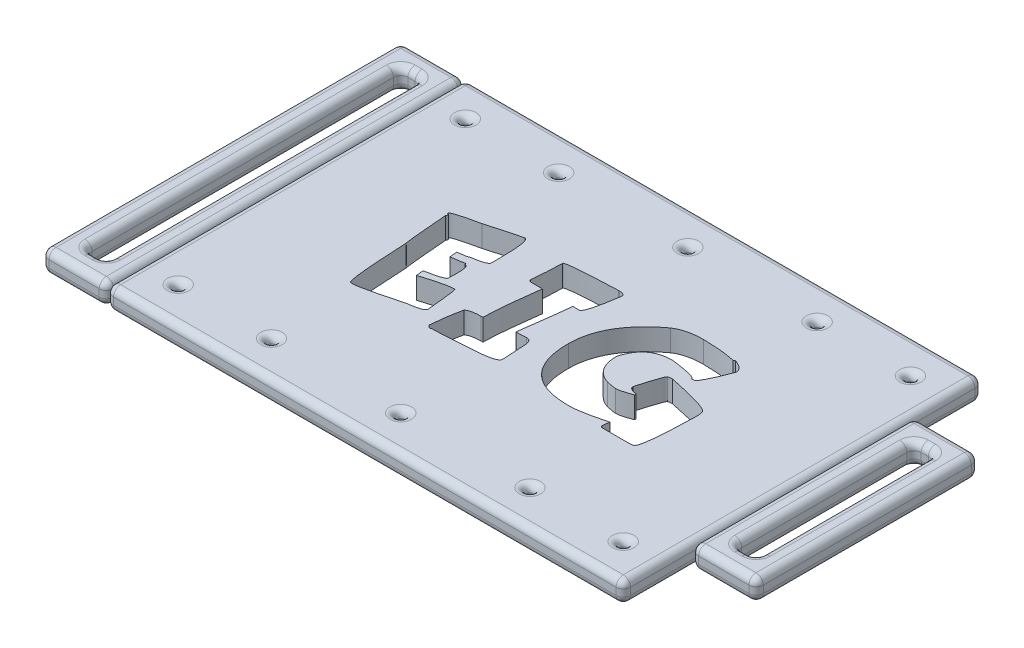
from build123d import *

# Parameters (mm, degrees)
SKETCH1_W             = 72
SKETCH1_H             = 50
BOSS_EXTRUDE2_DEPTH   = 3
SKETCH8_W             = 9
SKETCH8_H             = 50
SKETCH8_W_2           = 3
SKETCH8_H_2           = 44
BOSS_EXTRUDE4_DEPTH   = 3
SKETCH8_H_3           = 31
SKETCH8_H_4           = 25
BOSS_EXTRUDE4_2_DEPTH = 3
SKETCH11_R            = 0.5
CUT_EXTRUDE10_DEPTH   = 3
FILLET1_R             = 1
FILLET2_R             = 1
FILLET3_R             = 1
CUT_EXTRUDE11_DEPTH   = 3


with BuildPart() as part:
    # Sketch1 → Boss-Extrude2 (new body)
    with BuildSketch(Plane(origin=(0, 0, 0), x_dir=(1, 0, 0), z_dir=(0, 1, 0))):
        with Locations((36, 25)):
            Rectangle(SKETCH1_W, SKETCH1_H)
    extrude(amount=BOSS_EXTRUDE2_DEPTH)

    # Sketch11 → Cut-Extrude10 (cut)
    with BuildSketch(Plane(origin=(0, 3, 0), x_dir=(1, 0, 0), z_dir=(0, 1, 0))):
        with Locations((5, 45)):
            Circle(SKETCH11_R)
        with Locations((18, 45)):
            Circle(SKETCH11_R)
        with Locations((36, 45)):
            Circle(SKETCH11_R)
        with Locations((54, 45)):
            Circle(SKETCH11_R)
        with Locations((67, 45)):
            Circle(SKETCH11_R)
        with Locations((5, 5)):
            Circle(SKETCH11_R)
        with Locations((18, 5)):
            Circle(SKETCH11_R)
        with Locations((36, 5)):
            Circle(SKETCH11_R)
        with Locations((54, 5)):
            Circle(SKETCH11_R)
        with Locations((67, 5)):
            Circle(SKETCH11_R)
    extrude(amount=-CUT_EXTRUDE10_DEPTH, mode=Mode.SUBTRACT)

    # Fillet2
    fillet2_edges = [part.edges().sort_by_distance(p)[0] for p in [
        (72, 3, -25),
        (36, 3, 0),
        (4.5, 0, -45),
        (4.5, 3, -45),
        (17.5, 0, -45),
        (17.5, 3, -45),
        (35.5, 0, -45),
        (35.5, 3, -45),
        (53.5, 0, -45),
        (53.5, 3, -45),
        (66.5, 0, -45),
        (66.5, 3, -45),
        (4.5, 0, -5),
        (4.5, 3, -5),
        (17.5, 0, -5),
        (17.5, 3, -5),
        (0, 3, -25),
        (35.5, 0, -5),
        (35.5, 3, -5),
        (36, 0, 0),
        (53.5, 0, -5),
        (53.5, 3, -5),
        (72, 0, -25),
        (66.5, 0, -5),
        (66.5, 3, -5),
        (36, 0, -50),
        (0, 0, -25),
        (36, 3, -50),
        (0, 1.5, 0),
        (72, 1.5, 0),
        (72, 1.5, -50),
        (0, 1.5, -50),
    ]]
    fillet(fillet2_edges, radius=FILLET2_R)

    # Sketch12 → Cut-Extrude11 (cut)
    with BuildSketch(Plane(origin=(0, 3, 0), x_dir=(1, 0, 0), z_dir=(0, 1, 0))):
        with BuildLine():
            add(Edge.make_bspline(
                [(23.513348997, 34.79509182), (23.542243468, 34.792696097), (23.602376153, 34.787710323), (23.680670266, 34.728234915), (23.752622118, 34.643763876), (23.814809543, 34.524984763), (23.879081124, 34.376891701), (23.93003553, 34.194053177), (23.981978375, 33.979608764), (24.030108491, 33.733452782), (24.062959299, 33.451890687), (24.101739128, 33.14031549), (24.130031679, 32.795064967), (24.151057694, 32.416995385), (24.168895563, 32.006155009), (24.184635116, 31.56124843), (24.1904745, 31.084533359), (24.192497759, 30.755394967), (24.193539317, 30.585957099)],
                knots=[0, 0, 0, 0, 8.5372e-05, 0.000177669, 0.000283972, 0.000418237, 0.000577177, 0.000768075, 0.000986269, 0.001239444, 0.001519767, 0.001836382, 0.002181377, 0.00255868, 0.002972318, 0.003415049, 0.003894164, 0.004402491, 0.004402491, 0.004402491, 0.004402491], degree=3))
            Line((24.193539317, 30.585957099), (24.193539317, 29.401109446))
            add(Edge.make_bspline(
                [(24.193539317, 29.401109446), (24.184209016, 29.36420994), (24.16261767, 29.278820407), (24.042697036, 29.171379196), (23.861950432, 29.078170215), (23.61347439, 28.980150936), (23.297207823, 28.883184781), (22.90894671, 28.794587687), (22.453197712, 28.7025152), (22.123948194, 28.650141354), (21.948179874, 28.622181821)],
                knots=[0, 0, 0, 0, 0.000112179, 0.000259595, 0.000460992, 0.000725154, 0.001058277, 0.001452989, 0.001919159, 0.002453021, 0.002453021, 0.002453021, 0.002453021], degree=3))
            add(Edge.make_bspline(
                [(21.948179874, 28.622181821), (21.941487319, 28.611694935), (21.920724472, 28.579160634), (21.840196802, 28.555628052), (21.728795582, 28.517550708), (21.565973296, 28.482081462), (21.35974362, 28.447921814), (21.106405589, 28.406086047), (20.807299939, 28.368026038), (20.592675496, 28.340607959), (20.478091119, 28.325969908)],
                knots=[0, 0, 0, 0, 3.6569e-05, 0.000113452, 0.000236055, 0.0003975, 0.000609128, 0.000864643, 0.001167198, 0.00151374, 0.00151374, 0.00151374, 0.00151374], degree=3))
            Line((20.478091119, 28.325969908), (20.576828423, 27.291056679))
            add(Edge.make_bspline(
                [(20.576828423, 27.291056679), (20.769603215, 27.312915091), (21.136262888, 27.354490018), (21.651377555, 27.433162748), (22.10621298, 27.506220944), (22.384821703, 27.568935321), (22.515005141, 27.598239404)],
                knots=[0, 0, 0, 0, 0.000581959, 0.001106892, 0.001563204, 0.001963434, 0.001963434, 0.001963434, 0.001963434], degree=3))
            Line((22.515005141, 27.598239404), (22.515005141, 27.426363356))
            add(Edge.make_bspline(
                [(22.515005141, 27.426363356), (22.569513585, 27.428024826), (22.680595696, 27.431410716), (22.823511911, 27.300178967), (22.918949629, 27.094492927), (22.990925857, 26.804631139), (23.039520424, 26.428431763), (23.056847004, 25.963741095), (23.052586762, 25.409822536), (23.031186195, 25.011508555), (23.019662475, 24.797025507)],
                knots=[0, 0, 0, 0, 0.000157927, 0.000321838, 0.000541041, 0.000836439, 0.001212944, 0.001677893, 0.002230102, 0.002874388, 0.002874388, 0.002874388, 0.002874388], degree=3))
            Line((23.019662475, 24.797025507), (23.019662475, 24.599550898))
            add(Edge.make_bspline(
                [(23.019662475, 24.599550898), (23.008819632, 24.566086922), (22.981060121, 24.480413482), (22.83412265, 24.384867185), (22.626435579, 24.287627128), (22.336436559, 24.175765086), (21.963690683, 24.071499023), (21.508213914, 23.95886194), (20.972414972, 23.837332281), (20.585639802, 23.764426892), (20.379353814, 23.725542906)],
                knots=[0, 0, 0, 0, 0.00010324, 0.000264311, 0.000496548, 0.00080216, 0.001190966, 0.001658382, 0.002209331, 0.002839026, 0.002839026, 0.002839026, 0.002839026], degree=3))
            Line((20.379353814, 23.725542906), (20.478091119, 22.712571301))
            add(Edge.make_bspline(
                [(20.478091119, 22.712571301), (20.75449041, 22.79773034), (21.279406431, 22.959457758), (22.028949194, 23.17281952), (22.695167015, 23.360466683), (23.282403213, 23.501585355), (23.788113289, 23.61067601), (24.212515467, 23.680643267), (24.557311674, 23.721398433), (24.760307361, 23.714080972), (24.848131076, 23.710915157)],
                knots=[0, 0, 0, 0, 0.000867627, 0.00164773, 0.002337952, 0.002943747, 0.003459427, 0.003889284, 0.004234608, 0.004497933, 0.004497933, 0.004497933, 0.004497933], degree=3))
            add(Edge.make_bspline(
                [(24.848131076, 23.710915157), (24.85333327, 23.705013237), (24.86985153, 23.68627317), (24.884274937, 23.632963236), (24.907077567, 23.551187883), (24.926950639, 23.431764754), (24.952130518, 23.280735794), (24.982971904, 23.095777505), (25.009631065, 22.878271252), (25.044822149, 22.627600609), (25.075985436, 22.341985436), (25.112317328, 22.022594015), (25.153914036, 21.670590822), (25.192654863, 21.285099399), (25.237913391, 20.866034631), (25.280296503, 20.41230089), (25.328280569, 19.925972804), (25.361323911, 19.590766251), (25.378386971, 19.417670881)],
                knots=[0, 0, 0, 0, 2.3416e-05, 7.4351e-05, 0.000161275, 0.000280337, 0.000436047, 0.000621219, 0.000842577, 0.001093418, 0.001380551, 0.001704433, 0.002057796, 0.002443876, 0.002866707, 0.003322285, 0.003810976, 0.004332779, 0.004332779, 0.004332779, 0.004332779], degree=3))
            add(Edge.make_bspline(
                [(25.378386971, 19.417670881), (25.369810611, 19.37554961), (25.35067606, 19.281573661), (25.223801087, 19.167571679), (25.047096011, 19.058734946), (24.793778268, 18.965433868), (24.47696192, 18.864559693), (24.085031676, 18.783263416), (23.626039717, 18.696448288), (23.295432633, 18.651722256), (23.118399779, 18.627772445)],
                knots=[0, 0, 0, 0, 0.000126098, 0.000281335, 0.000488332, 0.000752493, 0.001085616, 0.00148663, 0.001951421, 0.002487209, 0.002487209, 0.002487209, 0.002487209], degree=3))
            add(Edge.make_bspline(
                [(23.118399779, 18.627772445), (22.91228221, 18.573331934), (22.512040938, 18.467618774), (21.929813856, 18.306532553), (21.377335569, 18.167169391), (20.858829955, 18.03006841), (20.37221079, 17.906708796), (19.918451981, 17.790677036), (19.495243468, 17.695523039), (19.106093372, 17.60135041), (18.748693093, 17.521864932), (18.423398298, 17.451434505), (18.130262753, 17.394546967), (17.87155008, 17.3408066), (17.644417742, 17.304241921), (17.450268872, 17.28036179), (17.288539063, 17.257565299), (17.190563957, 17.25677531), (17.146621327, 17.256420994)],
                knots=[0, 0, 0, 0, 0.000639556, 0.001241897, 0.001812215, 0.002348839, 0.002850853, 0.003318269, 0.003753813, 0.004152083, 0.004519383, 0.004852184, 0.005150533, 0.005415175, 0.005644835, 0.005840336, 0.006002277, 0.006133977, 0.006133977, 0.006133977, 0.006133977], degree=3))
            Line((17.146621327, 17.256420994), (16.751672109, 17.256420994))
            add(Edge.make_bspline(
                [(16.751672109, 17.256420994), (16.730669501, 17.265810672), (16.672771262, 17.291695354), (16.626214282, 17.413230159), (16.565690949, 17.577147799), (16.516436425, 17.817059205), (16.455445009, 18.118972323), (16.404330393, 18.492106019), (16.349078333, 18.930791823), (16.295018392, 19.43564583), (16.240137603, 20.00736166), (16.186007747, 20.647416534), (16.130002558, 21.355502045), (16.081942628, 22.131165965), (16.023982746, 22.973136637), (15.975150356, 23.882727684), (15.92317841, 24.860308587), (15.890767828, 25.534491992), (15.87400718, 25.883135856)],
                knots=[0, 0, 0, 0, 6.7132e-05, 0.000185065, 0.00036317, 0.000603556, 0.00091267, 0.001289689, 0.001731937, 0.002239567, 0.00281268, 0.003454991, 0.004166554, 0.004943513, 0.005786396, 0.006698411, 0.007676155, 0.008723291, 0.008723291, 0.008723291, 0.008723291], degree=3))
            add(Edge.make_bspline(
                [(15.87400718, 25.883135856), (15.868685337, 25.891501076), (15.849900177, 25.921028816), (15.845215108, 26.000247032), (15.817694861, 26.118442844), (15.79939398, 26.28799525), (15.772810246, 26.502162179), (15.744450603, 26.764445796), (15.710857215, 27.07396284), (15.675261416, 27.430016754), (15.633582176, 27.83324328), (15.594958266, 28.28331702), (15.550611113, 28.780615984), (15.503227126, 29.325514775), (15.452174961, 29.916732018), (15.397166184, 30.555463101), (15.337986133, 31.240374994), (15.300765403, 31.713486246), (15.281583353, 31.957308551)],
                knots=[0, 0, 0, 0, 2.9483e-05, 0.00010407, 0.000230327, 0.000396346, 0.000613618, 0.000878538, 0.001187479, 0.00154772, 0.001951989, 0.002403588, 0.002902863, 0.003449817, 0.004044449, 0.004683116, 0.005373106, 0.00610683, 0.00610683, 0.00610683, 0.00610683], degree=3))
            add(Edge.make_bspline(
                [(15.281583353, 31.957308551), (15.309666092, 32.010996214), (15.3586632, 32.104667283), (15.37384172, 32.20899029), (15.380320657, 32.253520464)],
                knots=[0, 0, 0, 0, 0.000180083, 0.000314199, 0.000314199, 0.000314199, 0.000314199], degree=3))
            add(Edge.make_bspline(
                [(15.380320657, 32.253520464), (15.350154431, 32.254156821), (15.296455706, 32.255289595), (15.231955281, 32.298031545), (15.184396146, 32.357261132), (15.18339229, 32.408490949), (15.182846048, 32.436367324)],
                knots=[0, 0, 0, 0, 8.845e-05, 0.000157448, 0.000225471, 0.000306669, 0.000306669, 0.000306669, 0.000306669], degree=3))
            add(Edge.make_bspline(
                [(15.182846048, 32.436367324), (15.186792162, 32.45029108), (15.196702879, 32.485260772), (15.24574909, 32.530239841), (15.318285077, 32.577405735), (15.41635581, 32.632849165), (15.5461687, 32.685579108), (15.702492123, 32.743504122), (15.886547534, 32.805971441), (16.098840759, 32.871380149), (16.340283527, 32.940720117), (16.609917875, 33.013062144), (16.907237513, 33.090349938), (17.232775314, 33.170609932), (17.587591911, 33.25435747), (17.96994242, 33.342842295), (18.381658299, 33.428863454), (18.664299453, 33.490558757), (18.810527754, 33.522477674)],
                knots=[0, 0, 0, 0, 4.2803e-05, 0.000107501, 0.00019169, 0.000304642, 0.000443894, 0.000611675, 0.000804801, 0.001026883, 0.001278043, 0.001558366, 0.001864371, 0.002199635, 0.002564193, 0.002958074, 0.003376949, 0.003825964, 0.003825964, 0.003825964, 0.003825964], degree=3))
            add(Edge.make_bspline(
                [(18.810527754, 33.522477674), (18.896948338, 33.550919238), (19.100602368, 33.617943077), (19.454865463, 33.721717338), (19.902095069, 33.850182197), (20.442931017, 34.000480481), (21.078918937, 34.166597467), (21.807606349, 34.357761588), (22.629425268, 34.5690031), (23.20858824, 34.717140559), (23.513348997, 34.79509182)],
                knots=[0, 0, 0, 0, 0.000272926, 0.000643163, 0.001107306, 0.001668917, 0.002327084, 0.003079249, 0.003928958, 0.004872675, 0.004872675, 0.004872675, 0.004872675], degree=3))
        make_face()
        with BuildLine():
            Line((36.338227769, 34.966967869), (36.510103817, 34.966967869))
            add(Edge.make_bspline(
                [(36.510103817, 34.966967869), (36.599487286, 34.963155053), (36.767654422, 34.955981576), (36.999571828, 34.893239834), (37.187828047, 34.775117375), (37.272464951, 34.663963499), (37.314630002, 34.608588023)],
                knots=[0, 0, 0, 0, 0.000267857, 0.000503949, 0.000712907, 0.000920355, 0.000920355, 0.000920355, 0.000920355], degree=3))
            add(Edge.make_bspline(
                [(37.314630002, 34.608588023), (37.285436684, 34.417199266), (37.228894642, 34.046514745), (37.145802535, 33.508577373), (37.061684859, 33.007538458), (36.977873563, 32.543009913), (36.893979299, 32.115044979), (36.810582914, 31.724748512), (36.726957312, 31.37219528), (36.641463106, 31.058355985), (36.564223188, 30.778520038), (36.478495944, 30.538242488), (36.399595451, 30.332089088), (36.321362948, 30.163210319), (36.239544312, 30.031838941), (36.16217724, 29.936355405), (36.081532701, 29.870479516), (36.022166675, 29.862123991), (35.994475672, 29.858226596)],
                knots=[0, 0, 0, 0, 0.000580809, 0.001124919, 0.00163293, 0.002104916, 0.002540967, 0.002941197, 0.003302198, 0.003627747, 0.003917085, 0.004172678, 0.004392703, 0.004579171, 0.004730349, 0.0048549, 0.004949274, 0.005031778, 0.005031778, 0.005031778, 0.005031778], degree=3))
            Line((35.994475672, 29.858226596), (35.105839931, 29.858226596))
            Line((35.105839931, 29.858226596), (35.105839931, 29.770460103))
            add(Edge.make_bspline(
                [(35.105839931, 29.770460103), (35.104826732, 29.744847476), (35.102120593, 29.676439106), (35.089037921, 29.551119048), (35.077150556, 29.377528961), (35.047304186, 29.15757966), (35.02228843, 28.888647316), (34.978087563, 28.573688785), (34.936213664, 28.210042289), (34.88473951, 27.799274936), (34.826023605, 27.33974538), (34.75931337, 26.83413885), (34.692001186, 26.278908386), (34.608884602, 25.678616668), (34.527405053, 25.028230544), (34.429887129, 24.332843461), (34.332385381, 23.587718529), (34.263676183, 23.075806916), (34.228175003, 22.811308605)],
                knots=[0, 0, 0, 0, 7.6883e-05, 0.000205345, 0.000377842, 0.000598747, 0.000870937, 0.001187996, 0.001552682, 0.001969076, 0.002429922, 0.002942481, 0.003499033, 0.004107767, 0.004760487, 0.005465404, 0.006214299, 0.00701491, 0.00701491, 0.00701491, 0.00701491], degree=3))
            Line((34.228175003, 22.811308605), (34.315941495, 22.811308605))
            add(Edge.make_bspline(
                [(34.315941495, 22.811308605), (34.398863721, 22.811658885), (34.583172363, 22.81243744), (34.885291051, 22.834875116), (35.242657243, 22.858724411), (35.498399365, 22.882576005), (35.636095826, 22.895418161)],
                knots=[0, 0, 0, 0, 0.000248699, 0.000552775, 0.00090842, 0.001323269, 0.001323269, 0.001323269, 0.001323269], degree=3))
            add(Edge.make_bspline(
                [(35.636095826, 22.895418161), (35.69877837, 22.892427463), (35.818323504, 22.886723748), (35.983665382, 22.829289047), (36.125374145, 22.739803496), (36.237053727, 22.608726641), (36.325474074, 22.444464165), (36.385748749, 22.243138767), (36.421492254, 22.008073558), (36.42443464, 21.839924721), (36.425994262, 21.750796817)],
                knots=[0, 0, 0, 0, 0.000187398, 0.000357396, 0.000518675, 0.000684492, 0.000867777, 0.001074807, 0.00131169, 0.001578872, 0.001578872, 0.001578872, 0.001578872], degree=3))
            add(Edge.make_bspline(
                [(36.425994262, 21.750796817), (36.432389722, 21.688655592), (36.447294686, 21.54383213), (36.464353315, 21.296224664), (36.481773514, 20.988920007), (36.503994718, 20.622020702), (36.530210464, 20.195483338), (36.555520487, 19.709081107), (36.580212477, 19.162876307), (36.59896079, 18.778919813), (36.608841122, 18.576575324)],
                knots=[0, 0, 0, 0, 0.000187398, 0.000436741, 0.000744467, 0.001110819, 0.001539446, 0.002026491, 0.002571976, 0.003179732, 0.003179732, 0.003179732, 0.003179732], degree=3))
            add(Edge.make_bspline(
                [(36.608841122, 18.576575324), (36.606378334, 18.54415662), (36.601360186, 18.478100647), (36.545417796, 18.387151325), (36.468930381, 18.297535337), (36.354670671, 18.219591493), (36.21509947, 18.140955379), (36.040827285, 18.075601306), (35.841030666, 18.003936584), (35.606882248, 17.943377327), (35.343554443, 17.885293769), (35.047968662, 17.834974248), (34.722402278, 17.787542099), (34.365080506, 17.744243262), (33.977354094, 17.704476621), (33.559357727, 17.666811395), (33.109299445, 17.638953584), (32.798326624, 17.623037135), (32.637407319, 17.61480084)],
                knots=[0, 0, 0, 0, 9.6199e-05, 0.000196014, 0.000312635, 0.000448681, 0.000607453, 0.000792842, 0.001005637, 0.001244264, 0.001517558, 0.001814558, 0.00214348, 0.002504536, 0.002894253, 0.003312745, 0.003763499, 0.004246893, 0.004246893, 0.004246893, 0.004246893], degree=3))
            add(Edge.make_bspline(
                [(32.637407319, 17.61480084), (32.355837816, 17.593865776), (31.817123445, 17.553811651), (31.046669523, 17.499879694), (30.350869087, 17.449595995), (29.730028131, 17.417024405), (29.18439137, 17.378420731), (28.713476244, 17.36482939), (28.317483359, 17.345906208), (28.078442984, 17.344719922), (27.971155448, 17.344187487)],
                knots=[0, 0, 0, 0, 0.000847037, 0.001620598, 0.002317041, 0.002939795, 0.003485671, 0.00395777, 0.00435299, 0.004674822, 0.004674822, 0.004674822, 0.004674822], degree=3))
            Line((27.971155448, 17.344187487), (27.799279399, 17.256420994))
            add(Edge.make_bspline(
                [(27.799279399, 17.256420994), (27.737153493, 17.283759571), (27.62656211, 17.332425437), (27.491562512, 17.423267852), (27.390178848, 17.509838113), (27.364377965, 17.582940378), (27.353133061, 17.61480084)],
                knots=[0, 0, 0, 0, 0.00020282, 0.000361043, 0.000490335, 0.000590217, 0.000590217, 0.000590217, 0.000590217], degree=3))
            add(Edge.make_bspline(
                [(27.353133061, 17.61480084), (27.384382269, 17.979582655), (27.446272373, 18.702045254), (27.588607272, 19.770002448), (27.757288248, 20.813457912), (27.90030487, 21.496517812), (27.971155448, 21.834906372)],
                knots=[0, 0, 0, 0, 0.001098208, 0.002175038, 0.003231342, 0.004268392, 0.004268392, 0.004268392, 0.004268392], degree=3))
            add(Edge.make_bspline(
                [(27.971155448, 21.834906372), (28.01619042, 21.872226196), (28.110944049, 21.950747147), (28.287206142, 22.033280409), (28.486912237, 22.111964333), (28.715718754, 22.176969706), (28.974263034, 22.223281969), (29.260256969, 22.254381696), (29.574959291, 22.277631758), (29.794699602, 22.279879911), (29.909332166, 22.281052711)],
                knots=[0, 0, 0, 0, 0.000174808, 0.000367796, 0.000579677, 0.000819283, 0.001079646, 0.00136678, 0.001682041, 0.002025871, 0.002025871, 0.002025871, 0.002025871], degree=3))
            Line((29.909332166, 22.281052711), (30.168974707, 22.281052711))
            add(Edge.make_bspline(
                [(30.168974707, 22.281052711), (30.171413774, 22.479782389), (30.176698631, 22.910380625), (30.213016674, 23.606525146), (30.266808639, 24.404045069), (30.350746962, 25.300803895), (30.447049316, 26.298478984), (30.575426036, 27.394897033), (30.714677017, 28.593882837), (30.824802242, 29.425637742), (30.882077462, 29.858226596)],
                knots=[0, 0, 0, 0, 0.000596182, 0.001291779, 0.002090876, 0.002994073, 0.003993648, 0.005097753, 0.006305677, 0.007614743, 0.007614743, 0.007614743, 0.007614743], degree=3))
            Line((30.882077462, 29.858226596), (29.463185827, 29.858226596))
            add(Edge.make_bspline(
                [(29.463185827, 29.858226596), (29.394278396, 29.859357451), (29.271033299, 29.861380053), (29.11154017, 29.91310525), (28.988918343, 29.994387317), (28.958626925, 30.077475698), (28.943900744, 30.117869137)],
                knots=[0, 0, 0, 0, 0.00020531, 0.00036721, 0.000500324, 0.000626263, 0.000626263, 0.000626263, 0.000626263], degree=3))
            add(Edge.make_bspline(
                [(28.943900744, 30.117869137), (28.965220858, 30.337231586), (29.006537771, 30.762340913), (29.05696083, 31.383003901), (29.101089733, 31.966889668), (29.137704039, 32.514232967), (29.167071671, 33.024996896), (29.190288377, 33.497912395), (29.200996835, 33.935659061), (29.202717084, 34.214853753), (29.203543285, 34.348945482)],
                knots=[0, 0, 0, 0, 0.000661178, 0.001281317, 0.001868071, 0.002417829, 0.002926984, 0.003402892, 0.003838206, 0.004240486, 0.004240486, 0.004240486, 0.004240486], degree=3))
            add(Edge.make_bspline(
                [(29.203543285, 34.348945482), (29.212236394, 34.364670041), (29.236034589, 34.40771749), (29.332832322, 34.445108467), (29.469970774, 34.487601722), (29.669141145, 34.524503658), (29.917949097, 34.569913564), (30.224791708, 34.607637303), (30.586519404, 34.649452933), (31.005277969, 34.682134553), (31.478978645, 34.725778835), (32.00834118, 34.759816414), (32.593428001, 34.796581339), (33.2345006, 34.834479846), (33.932037016, 34.864253542), (34.685116352, 34.903820484), (35.493449991, 34.934780917), (36.050549448, 34.956007012), (36.338227769, 34.966967869)],
                knots=[0, 0, 0, 0, 5.2741e-05, 0.000144384, 0.000293603, 0.000491551, 0.000747667, 0.001053847, 0.001418112, 0.001840246, 0.002313703, 0.002845219, 0.00343147, 0.004072478, 0.004771728, 0.005525944, 0.006334797, 0.007198462, 0.007198462, 0.007198462, 0.007198462], degree=3))
        make_face()
        with BuildLine():
            add(Edge.make_bspline(
                [(48.201332056, 34.966967869), (48.61348662, 34.961046831), (49.416658257, 34.949508418), (50.590974784, 34.868668774), (51.704074798, 34.734544826), (52.419709908, 34.593358838), (52.768846623, 34.524478467)],
                knots=[0, 0, 0, 0, 0.001236391, 0.002409373, 0.003529734, 0.004597021, 0.004597021, 0.004597021, 0.004597021], degree=3))
            Line((52.768846623, 34.524478467), (52.988262855, 34.634186583))
            add(Edge.make_bspline(
                [(52.988262855, 34.634186583), (53.10244291, 34.593541967), (53.318391256, 34.516670943), (53.61313883, 34.376491303), (53.864103794, 34.228730166), (54.068792094, 34.066564477), (54.230131164, 33.893613628), (54.345957776, 33.707773667), (54.42126976, 33.509758921), (54.428924884, 33.371967843), (54.43275305, 33.303061441)],
                knots=[0, 0, 0, 0, 0.000363383, 0.000687264, 0.00097764, 0.001235214, 0.00146817, 0.001683308, 0.001889204, 0.002095164, 0.002095164, 0.002095164, 0.002095164], degree=3))
            add(Edge.make_bspline(
                [(54.43275305, 33.303061441), (54.37203899, 33.145722376), (54.254199728, 32.840344686), (54.078959422, 32.397710185), (53.910304753, 31.986371299), (53.754600012, 31.603115206), (53.599667082, 31.254875258), (53.458775736, 30.933548422), (53.318167998, 30.646513571), (53.191193713, 30.3857592), (53.071826132, 30.155701262), (52.957487144, 29.957451525), (52.853722232, 29.788503298), (52.753530624, 29.653778504), (52.667069433, 29.543236797), (52.582791403, 29.467145387), (52.507483465, 29.412582473), (52.454889688, 29.404545053), (52.4324084, 29.401109446)],
                knots=[0, 0, 0, 0, 0.000505941, 0.000981975, 0.001428137, 0.001839684, 0.002222878, 0.002571536, 0.002892118, 0.003181594, 0.003441674, 0.003669376, 0.003868234, 0.004035736, 0.004173394, 0.004287289, 0.004377608, 0.004445039, 0.004445039, 0.004445039, 0.004445039], degree=3))
            Line((52.4324084, 29.401109446), (52.099627115, 29.401109446))
            add(Edge.make_bspline(
                [(52.099627115, 29.401109446), (52.085598355, 29.440018333), (52.049106625, 29.54122846), (51.862078402, 29.643607235), (51.60138035, 29.74807707), (51.232915586, 29.862262743), (50.762112612, 29.966426683), (50.18578996, 30.074822916), (49.507228881, 30.18917831), (49.018287406, 30.254736362), (48.757186511, 30.289745186)],
                knots=[0, 0, 0, 0, 0.000121066, 0.000314918, 0.000600159, 0.00097953, 0.001463864, 0.002048391, 0.002737964, 0.003528201, 0.003528201, 0.003528201, 0.003528201], degree=3))
            Line((48.757186511, 30.289745186), (48.424405225, 30.289745186))
            add(Edge.make_bspline(
                [(48.424405225, 30.289745186), (48.292699132, 30.286300075), (48.0336673, 30.279524432), (47.654168937, 30.245185976), (47.292593783, 30.177627555), (46.94871484, 30.087009196), (46.620023834, 29.969921435), (46.311298088, 29.823473198), (46.017685172, 29.653930824), (45.743816543, 29.456080482), (45.487877887, 29.232174378), (45.247608951, 28.98442666), (45.023146075, 28.7110845), (44.825275044, 28.404761515), (44.635283864, 28.07851528), (44.469821598, 27.72374898), (44.317756502, 27.344180818), (44.233127426, 27.079537265), (44.189671944, 26.943647645)],
                knots=[0, 0, 0, 0, 0.00039522, 0.000777296, 0.00114167, 0.001497372, 0.001843238, 0.002186776, 0.002521081, 0.002859046, 0.00319859, 0.003539961, 0.003893494, 0.004257612, 0.004632729, 0.005025318, 0.005430727, 0.005858604, 0.005858604, 0.005858604, 0.005858604], degree=3))
            Line((44.189671944, 26.943647645), (44.189671944, 26.833939529))
            add(Edge.make_bspline(
                [(44.189671944, 26.833939529), (44.197441099, 26.606745698), (44.212374585, 26.17004497), (44.324625718, 25.544510662), (44.518731254, 24.983060623), (44.789110809, 24.481739777), (45.139152895, 24.045696149), (45.57149138, 23.678231931), (46.075694647, 23.370331667), (46.452942809, 23.228215777), (46.647133745, 23.155060703)],
                knots=[0, 0, 0, 0, 0.000681379, 0.001309713, 0.001898389, 0.002456416, 0.003010403, 0.003565318, 0.004151091, 0.00477249, 0.00477249, 0.00477249, 0.00477249], degree=3))
            add(Edge.make_bspline(
                [(46.647133745, 23.155060703), (46.805515002, 23.122888496), (47.090197143, 23.065060615), (47.47009408, 22.994291142), (47.755482633, 22.950153212), (47.914796752, 22.939777567), (47.978258887, 22.93564447)],
                knots=[0, 0, 0, 0, 0.000484817, 0.000871433, 0.001159497, 0.001350219, 0.001350219, 0.001350219, 0.001350219], degree=3))
            add(Edge.make_bspline(
                [(47.978258887, 22.93564447), (48.040501117, 22.936997481), (48.172776971, 22.939872871), (48.381660656, 22.967840108), (48.6123732, 23.011854224), (48.864246404, 23.075738313), (49.140196564, 23.152525665), (49.438078331, 23.246920431), (49.756567653, 23.361930154), (49.975067346, 23.444860658), (50.088311653, 23.487841988)],
                knots=[0, 0, 0, 0, 0.000186647, 0.000396659, 0.000631188, 0.000891062, 0.001175881, 0.001490462, 0.00182821, 0.002191592, 0.002191592, 0.002191592, 0.002191592], degree=3))
            Line((50.088311653, 23.487841988), (50.088311653, 23.710915157))
            add(Edge.make_bspline(
                [(50.088311653, 23.710915157), (50.001498813, 23.722786852), (49.837610036, 23.745198714), (49.611219503, 23.799804492), (49.418782103, 23.86545708), (49.258461649, 23.939633232), (49.13347855, 24.032891084), (49.042634731, 24.139708274), (48.987637866, 24.262075688), (48.98029598, 24.347921764), (48.976602743, 24.391105477)],
                knots=[0, 0, 0, 0, 0.00026274, 0.000496012, 0.000697243, 0.000872242, 0.001023641, 0.001161299, 0.00128903, 0.001418322, 0.001418322, 0.001418322, 0.001418322], degree=3))
            add(Edge.make_bspline(
                [(48.976602743, 24.391105477), (49.016400825, 24.53506773), (49.093409064, 24.813630894), (49.211918137, 25.215117139), (49.319952816, 25.590216777), (49.429491924, 25.935831575), (49.518732508, 26.25814604), (49.619061797, 26.546678618), (49.700336947, 26.811684834), (49.781262726, 27.047644255), (49.854300994, 27.256115807), (49.919487707, 27.437301046), (49.981908142, 27.589118382), (50.035284882, 27.716081994), (50.087676245, 27.811974759), (50.124894575, 27.885793071), (50.164067395, 27.929221967), (50.191618731, 27.941255456), (50.201676706, 27.945648439)],
                knots=[0, 0, 0, 0, 0.000448076, 0.000867014, 0.001255821, 0.001619056, 0.001954619, 0.002258761, 0.002535168, 0.002786115, 0.00300702, 0.003197917, 0.003363613, 0.003499512, 0.003610733, 0.003691019, 0.003747908, 0.003780617, 0.003780617, 0.003780617, 0.003780617], degree=3))
            add(Edge.make_bspline(
                [(50.201676706, 27.945648439), (50.235355781, 27.962597245), (50.309796944, 28.000059342), (50.44112172, 28.034578289), (50.597417704, 28.05068676), (50.708734067, 28.053725172), (50.768501973, 28.055356555)],
                knots=[0, 0, 0, 0, 0.000112892, 0.000249527, 0.000404203, 0.000583542, 0.000583542, 0.000583542, 0.000583542], degree=3))
            add(Edge.make_bspline(
                [(50.768501973, 28.055356555), (51.015978618, 28.004277778), (51.494083787, 27.905597648), (52.188433703, 27.760279216), (52.833242686, 27.614726392), (53.430908334, 27.469697734), (53.982242175, 27.338070271), (54.484057955, 27.201861261), (54.937917131, 27.068517077), (55.347133684, 26.948073275), (55.706485813, 26.823100414), (56.016621443, 26.701641813), (56.28222583, 26.592345123), (56.495971024, 26.477143691), (56.666376604, 26.369843511), (56.788644643, 26.265977756), (56.87067178, 26.162948892), (56.884076277, 26.088915435), (56.890214851, 26.055011905)],
                knots=[0, 0, 0, 0, 0.000758081, 0.001464551, 0.002128152, 0.002741057, 0.00330959, 0.00382854, 0.004300725, 0.004728758, 0.005108094, 0.005441537, 0.005728205, 0.005968702, 0.006169535, 0.00633019, 0.006450925, 0.006552926, 0.006552926, 0.006552926, 0.006552926], degree=3))
            Line((56.890214851, 26.055011905), (56.999922967, 25.502814387))
            add(Edge.make_bspline(
                [(56.999922967, 25.502814387), (56.990680416, 25.189519459), (56.972768884, 24.58237189), (56.938432042, 23.701135561), (56.906811024, 22.878219141), (56.870856231, 22.113845134), (56.828732825, 21.408236448), (56.792578878, 20.760464412), (56.740448738, 20.172310037), (56.701352642, 19.640050129), (56.647988934, 19.167445761), (56.598753093, 18.752541363), (56.544427375, 18.397407971), (56.487531202, 18.100800524), (56.426073525, 17.860616158), (56.364862173, 17.681069476), (56.310782768, 17.54619031), (56.249574138, 17.498792694), (56.22465228, 17.479494163)],
                knots=[0, 0, 0, 0, 0.000940288, 0.001822224, 0.002645693, 0.003410867, 0.004117802, 0.004766328, 0.005357011, 0.00588908, 0.006367231, 0.006783624, 0.007142563, 0.007444499, 0.007690195, 0.007883321, 0.008019072, 0.008112306, 0.008112306, 0.008112306, 0.008112306], degree=3))
            add(Edge.make_bspline(
                [(56.22465228, 17.479494163), (56.212364088, 17.443270696), (56.181917036, 17.353518042), (55.998155392, 17.298437716), (55.758068134, 17.262196369), (55.560161307, 17.25853698), (55.445724655, 17.256420994)],
                knots=[0, 0, 0, 0, 0.000109586, 0.000271527, 0.000519822, 0.000860232, 0.000860232, 0.000860232, 0.000860232], degree=3))
            Line((55.445724655, 17.256420994), (51.766845829, 17.256420994))
            add(Edge.make_bspline(
                [(51.766845829, 17.256420994), (51.732513684, 17.260111469), (51.666534951, 17.267203741), (51.587847031, 17.341177453), (51.550062902, 17.454391394), (51.546061396, 17.540150673), (51.54377266, 17.589202279)],
                knots=[0, 0, 0, 0, 0.000101146, 0.00019438, 0.000304392, 0.000451399, 0.000451399, 0.000451399, 0.000451399], degree=3))
            add(Edge.make_bspline(
                [(51.54377266, 17.589202279), (51.545974237, 17.61970084), (51.552509289, 17.710231257), (51.577922702, 17.888940389), (51.607464576, 18.155409092), (51.639128157, 18.360937775), (51.657137713, 18.47783802)],
                knots=[0, 0, 0, 0, 9.1716e-05, 0.000272244, 0.000541221, 0.000896001, 0.000896001, 0.000896001, 0.000896001], degree=3))
            add(Edge.make_bspline(
                [(51.657137713, 18.47783802), (51.390469834, 18.407216009), (50.876570605, 18.271119388), (50.128720996, 18.092668172), (49.436706795, 17.937914334), (48.796425352, 17.812882027), (48.211379318, 17.713250628), (47.678466661, 17.642298455), (47.200013299, 17.60008513), (46.898312145, 17.59267633), (46.756841861, 17.589202279)],
                knots=[0, 0, 0, 0, 0.000827551, 0.001594785, 0.002306377, 0.002954718, 0.003551706, 0.004086495, 0.00456724, 0.004991697, 0.004991697, 0.004991697, 0.004991697], degree=3))
            add(Edge.make_bspline(
                [(46.756841861, 17.589202279), (46.455526432, 17.594490762), (45.869832875, 17.604770456), (45.021254264, 17.693353975), (44.230336961, 17.837153685), (43.499016778, 18.043635285), (42.821584206, 18.299033629), (42.206147608, 18.625369833), (41.645837268, 19.004455597), (41.14957334, 19.449399527), (40.704629409, 19.945663455), (40.325543645, 20.505973795), (39.999207441, 21.121410393), (39.743809098, 21.798842965), (39.537327498, 22.530163148), (39.393527788, 23.321080451), (39.304944268, 24.169659063), (39.294664575, 24.75535262), (39.289376092, 25.056668048)],
                knots=[0, 0, 0, 0, 0.000903737, 0.001756674, 0.002556407, 0.003312403, 0.004033636, 0.004723945, 0.005397457, 0.006057988, 0.006718518, 0.00739203, 0.00808234, 0.008803572, 0.009559568, 0.010359301, 0.011212238, 0.012115976, 0.012115976, 0.012115976, 0.012115976], degree=3))
            add(Edge.make_bspline(
                [(39.289376092, 25.056668048), (39.294205788, 25.268882298), (39.303799811, 25.690438452), (39.362120029, 26.318815762), (39.465780362, 26.936610524), (39.60677292, 27.545972706), (39.797099212, 28.142720145), (40.01765703, 28.733511133), (40.286736114, 29.311494557), (40.595472148, 29.879979104), (40.942613477, 30.439853153), (41.332743881, 30.989142343), (41.76014425, 31.531849802), (42.233274174, 32.061294101), (42.747162941, 32.581032128), (43.29919438, 33.09305706), (43.892833335, 33.595094301), (44.310233915, 33.915452268), (44.52245323, 34.078332128)],
                knots=[0, 0, 0, 0, 0.000636685, 0.001264753, 0.0018912, 0.00251478, 0.003139357, 0.003768967, 0.004405452, 0.005050163, 0.005708757, 0.00638044, 0.007070362, 0.00778009, 0.008509317, 0.009262335, 0.010038201, 0.01084068, 0.01084068, 0.01084068, 0.01084068], degree=3))
            add(Edge.make_bspline(
                [(44.52245323, 34.078332128), (44.640510613, 34.150439373), (44.881118693, 34.297398295), (45.27490665, 34.471710952), (45.692803036, 34.628188855), (46.140267221, 34.749672282), (46.614835946, 34.850369413), (47.118478821, 34.917873911), (47.650907815, 34.95819103), (48.014754583, 34.963992781), (48.201332056, 34.966967869)],
                knots=[0, 0, 0, 0, 0.000414591, 0.000844961, 0.001289245, 0.001752393, 0.00223436, 0.002743778, 0.003275558, 0.00383526, 0.00383526, 0.00383526, 0.00383526], degree=3))
        make_face()
    extrude(amount=-CUT_EXTRUDE11_DEPTH, mode=Mode.SUBTRACT)


with BuildPart() as body_2:
    # Sketch8 → Boss-Extrude4 (new body)
    with BuildSketch(Plane(origin=(0, 0, 0), x_dir=(-1, 0, 0), z_dir=(0, -1, 0))):
        with Locations((4.5, 25)):
            Rectangle(SKETCH8_W, SKETCH8_H)
        with Locations((4.5, 25)):
            Rectangle(SKETCH8_W_2, SKETCH8_H_2, mode=Mode.SUBTRACT)
    extrude(amount=-BOSS_EXTRUDE4_DEPTH)

    # Fillet1
    fillet1_edges = [body_2.edges().sort_by_distance(p)[0] for p in [
        (-9, 3, -25),
        (-4.5, 3, -50),
        (-3, 3, -25),
        (-3, 1.5, -3),
        (-4.5, 3, -47),
        (-3, 1.5, -47),
        (-6, 3, -25),
        (-6, 1.5, -47),
        (-4.5, 3, -3),
        (-6, 1.5, -3),
        (-3, 0, -25),
        (-4.5, 0, -3),
        (-6, 0, -25),
        (-4.5, 0, -47),
        (0, 3, -25),
        (-4.5, 0, -50),
        (-9, 0, -25),
        (-4.5, 0, 0),
        (0, 0, -25),
        (-4.5, 3, 0),
        (0, 1.5, -50),
        (-9, 1.5, -50),
        (-9, 1.5, 0),
        (0, 1.5, 0),
    ]]
    fillet(fillet1_edges, radius=FILLET1_R)


with BuildPart() as body_3:
    # Sketch8 → Boss-Extrude4 2 (new body)
    with BuildSketch(Plane(origin=(0, 0, 0), x_dir=(-1, 0, 0), z_dir=(0, -1, 0))):
        with Locations((-76.5, 25)):
            Rectangle(SKETCH8_W, SKETCH8_H_3)
        with Locations((-76.5, 25)):
            Rectangle(SKETCH8_W_2, SKETCH8_H_4, mode=Mode.SUBTRACT)
    extrude(amount=-BOSS_EXTRUDE4_2_DEPTH)

    # Fillet3
    fillet3_edges = [body_3.edges().sort_by_distance(p)[0] for p in [
        (81, 3, -25),
        (76.5, 3, -9.5),
        (78, 3, -25),
        (78, 1.5, -12.5),
        (76.5, 3, -37.5),
        (78, 1.5, -37.5),
        (75, 3, -25),
        (75, 1.5, -37.5),
        (76.5, 3, -12.5),
        (75, 1.5, -12.5),
        (78, 0, -25),
        (76.5, 0, -12.5),
        (75, 0, -25),
        (76.5, 0, -37.5),
        (72, 3, -25),
        (76.5, 0, -9.5),
        (81, 0, -25),
        (76.5, 0, -40.5),
        (72, 0, -25),
        (76.5, 3, -40.5),
        (72, 1.5, -9.5),
        (81, 1.5, -9.5),
        (81, 1.5, -40.5),
        (72, 1.5, -40.5),
    ]]
    fillet(fillet3_edges, radius=FILLET3_R)


solid = Compound([part.part, body_2.part, body_3.part])
